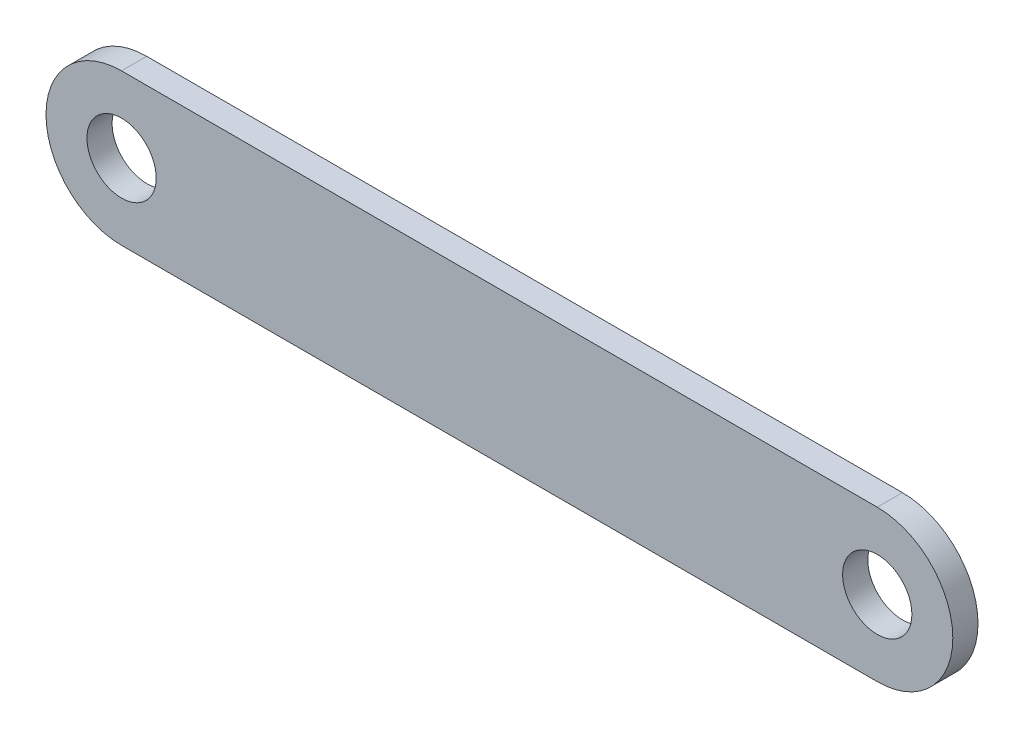
from build123d import *

# Parameters (mm, degrees)
SKETCH1_R  = 2.75
MAIN_DEPTH = 2


with BuildPart() as part:
    # Sketch1 → Main (new body)
    with BuildSketch(Plane.XY):
        with BuildLine():
            Line((-30, 6), (30, 6))
            ThreePointArc((30, 6), (36, 0), (30, -6))
            Line((30, -6), (-30, -6))
            ThreePointArc((-30, -6), (-36, 0), (-30, 6))
        make_face()
        with Locations((30, 0)):
            Circle(SKETCH1_R, mode=Mode.SUBTRACT)
        with Locations((-30, 0)):
            Circle(SKETCH1_R, mode=Mode.SUBTRACT)
    extrude(amount=MAIN_DEPTH)


solid = part.part
